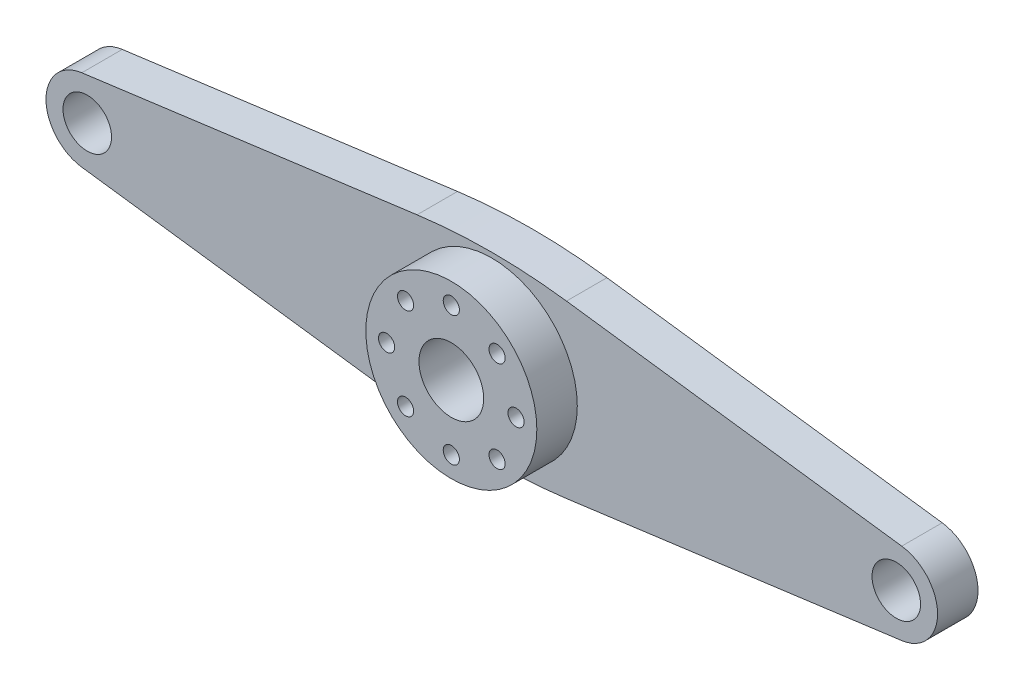
from build123d import *

# Parameters (mm, degrees)
SZKIC1_R                    = 3
SZKIC1_R_2                  = 1
SZKIC1_R_3                  = 4
DODANIE_WYCI_GNI_CIE1_DEPTH = 5
SZKIC1_3_R                  = 10.570763761
SZKIC1_3_R_2                = 1
SZKIC1_3_R_3                = 4
DODANIE_WYCI_GNI_CIE2_DEPTH = 10


with BuildPart() as part:
    # Szkic1 → Dodanie-wyci_gni_cie1 (new body)
    with BuildSketch(Plane.XY):
        with BuildLine():
            Line((-9.235111676, 10.570763761), (-50.67287635, 5.055665151))
            ThreePointArc((-50.67287635, 5.055665151), (-55.100246338, 0), (-50.67287635, -5.055665151))
            Line((-50.67287635, -5.055665151), (-9.235111676, -10.570763761))
            ThreePointArc((-9.235111676, -10.570763761), (0, -11.182632843), (9.235111676, -10.570763761))
            Line((9.235111676, -10.570763761), (50.67287635, -5.055665151))
            ThreePointArc((50.67287635, -5.055665151), (55.100246338, 0), (50.67287635, 5.055665151))
            Line((50.67287635, 5.055665151), (9.235111676, 10.570763761))
            ThreePointArc((9.235111676, 10.570763761), (0, 11.182632843), (-9.235111676, 10.570763761))
        make_face()
        with Locations((-50, 0)):
            Circle(SZKIC1_R, mode=Mode.SUBTRACT)
        with Locations((50, 0)):
            Circle(SZKIC1_R, mode=Mode.SUBTRACT)
        with Locations((0, 8)):
            Circle(SZKIC1_R_2, mode=Mode.SUBTRACT)
        with Locations((0, -8)):
            Circle(SZKIC1_R_2, mode=Mode.SUBTRACT)
        with Locations((-5.656854249, -5.656854249)):
            Circle(SZKIC1_R_2, mode=Mode.SUBTRACT)
        with Locations((-8, 0)):
            Circle(SZKIC1_R_2, mode=Mode.SUBTRACT)
        Circle(SZKIC1_R_3, mode=Mode.SUBTRACT)
        with Locations((5.656854249, -5.656854249)):
            Circle(SZKIC1_R_2, mode=Mode.SUBTRACT)
        with Locations((8, 0)):
            Circle(SZKIC1_R_2, mode=Mode.SUBTRACT)
        with Locations((-5.656854249, 5.656854249)):
            Circle(SZKIC1_R_2, mode=Mode.SUBTRACT)
        with Locations((5.656854249, 5.656854249)):
            Circle(SZKIC1_R_2, mode=Mode.SUBTRACT)
    extrude(amount=DODANIE_WYCI_GNI_CIE1_DEPTH)

    # Szkic1_3 → Dodanie-wyci_gni_cie2 (add)
    with BuildSketch(Plane.XY):
        Circle(SZKIC1_3_R)
        with Locations((0, -8)):
            Circle(SZKIC1_3_R_2, mode=Mode.SUBTRACT)
        with Locations((-5.656854249, -5.656854249)):
            Circle(SZKIC1_3_R_2, mode=Mode.SUBTRACT)
        with Locations((-8, 0)):
            Circle(SZKIC1_3_R_2, mode=Mode.SUBTRACT)
        Circle(SZKIC1_3_R_3, mode=Mode.SUBTRACT)
        with Locations((5.656854249, -5.656854249)):
            Circle(SZKIC1_3_R_2, mode=Mode.SUBTRACT)
        with Locations((8, 0)):
            Circle(SZKIC1_3_R_2, mode=Mode.SUBTRACT)
        with Locations((-5.656854249, 5.656854249)):
            Circle(SZKIC1_3_R_2, mode=Mode.SUBTRACT)
        with Locations((5.656854249, 5.656854249)):
            Circle(SZKIC1_3_R_2, mode=Mode.SUBTRACT)
        with Locations((0, 8)):
            Circle(SZKIC1_3_R_2, mode=Mode.SUBTRACT)
    extrude(amount=DODANIE_WYCI_GNI_CIE2_DEPTH)


solid = part.part
